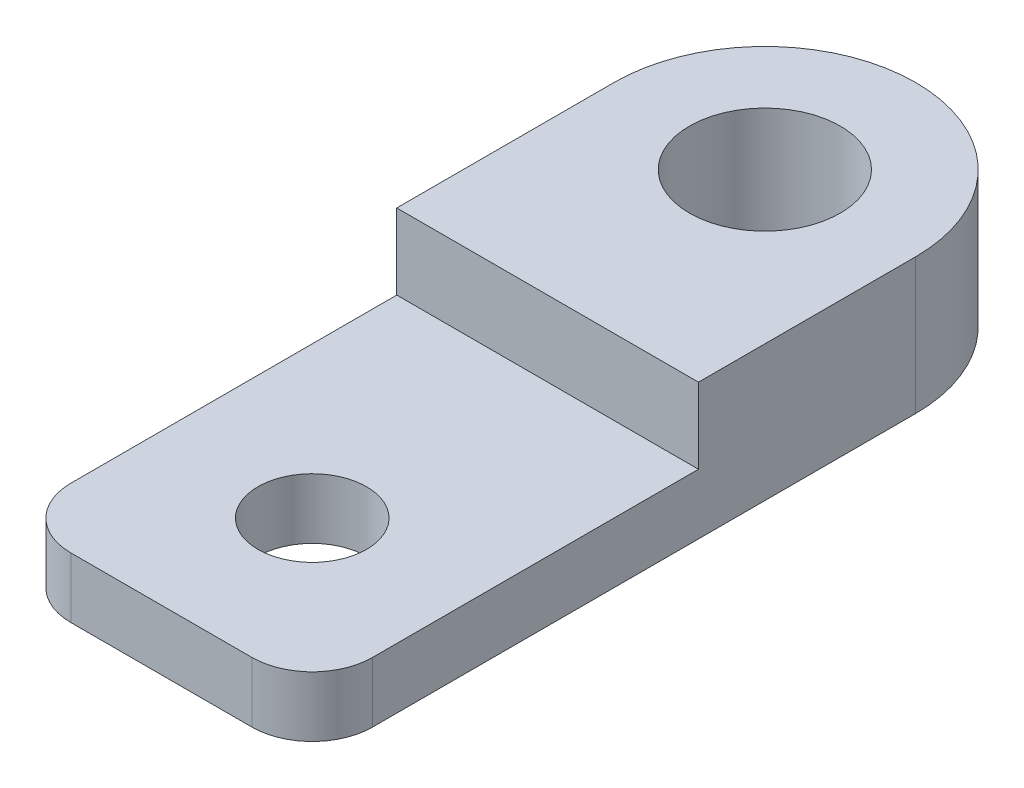
from build123d import *

# Parameters (mm, degrees)
SKETCH1_R           = 3.175
SKETCH1_R_2         = 2.286
BOSS_EXTRUDE1_DEPTH = 2.54
SKETCH2_R           = 3.175
BOSS_EXTRUDE2_DEPTH = 3.175


with BuildPart() as part:
    # Sketch1 → Boss-Extrude1 (new body)
    with BuildSketch(Plane(origin=(0, 0, 0), x_dir=(1, 0, 0), z_dir=(0, 1, 0))):
        with BuildLine():
            Line((2.54, 0), (10.16, 0))
            ThreePointArc((10.16, 0), (11.956051224, 0.743948776), (12.7, 2.54))
            Line((12.7, 2.54), (12.7, 25.4))
            ThreePointArc((12.7, 25.4), (6.35, 31.75), (0, 25.4))
            Line((0, 25.4), (0, 2.54))
            ThreePointArc((0, 2.54), (0.743948776, 0.743948776), (2.54, 0))
        make_face()
        with Locations((6.35, 25.4)):
            Circle(SKETCH1_R, mode=Mode.SUBTRACT)
        with Locations((6.35, 6.35)):
            Circle(SKETCH1_R_2, mode=Mode.SUBTRACT)
    extrude(amount=BOSS_EXTRUDE1_DEPTH)

    # Sketch2 → Boss-Extrude2 (add)
    with BuildSketch(Plane(origin=(0, 2.54, 0), x_dir=(1, 0, 0), z_dir=(0, 1, 0))):
        with BuildLine():
            Line((0, 25.4), (0, 16.256))
            Line((0, 16.256), (12.7, 16.256))
            Line((12.7, 16.256), (12.7, 25.4))
            ThreePointArc((12.7, 25.4), (6.35, 31.75), (0, 25.4))
        make_face()
        with Locations((6.35, 25.4)):
            Circle(SKETCH2_R, mode=Mode.SUBTRACT)
    extrude(amount=BOSS_EXTRUDE2_DEPTH)


solid = part.part
